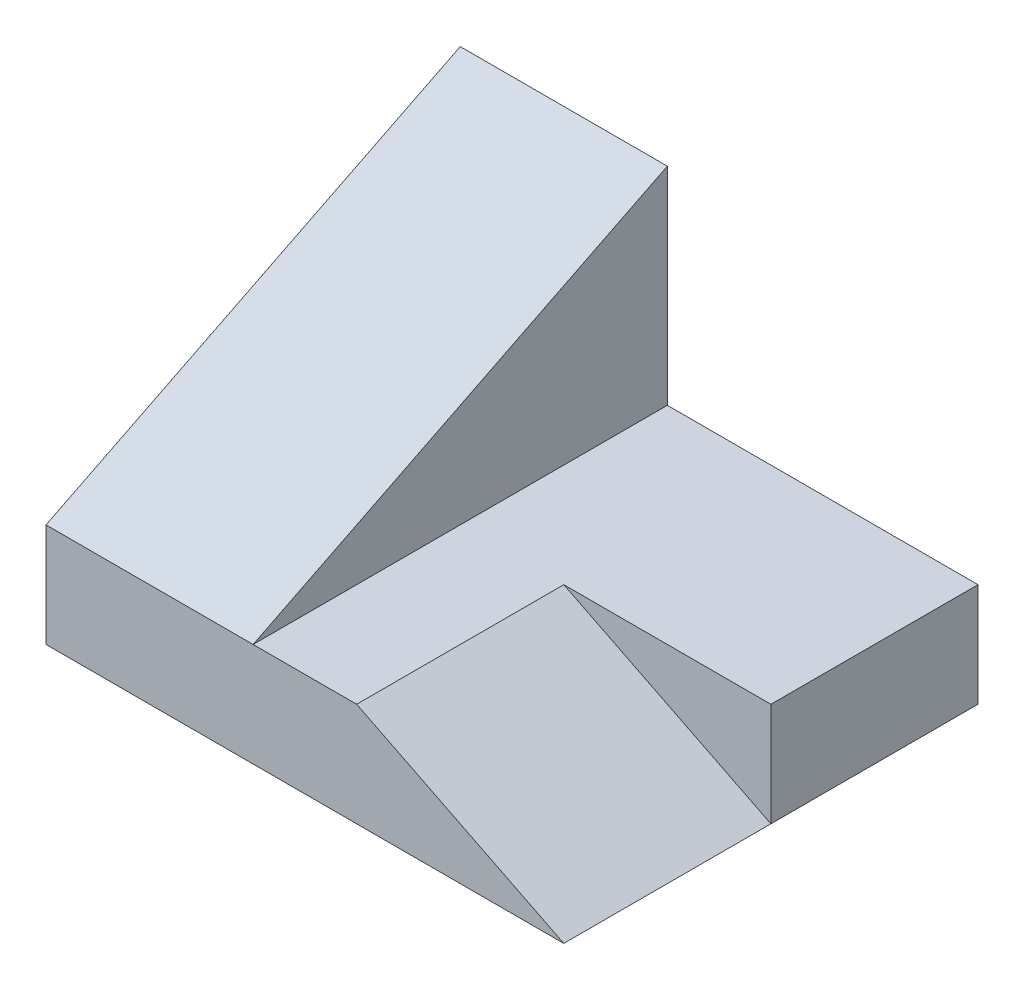
from build123d import *

# Parameters (mm, degrees)
SKETCH5_W               = 50
SKETCH5_H               = 40
BOSS_EXTRUDE5_DEPTH     = 10
SKETCH6_W               = 20
SKETCH6_H               = 40
BOSS_EXTRUDE6_DEPTH     = 20
CUT_EXTRUDE1_DEPTH      = 31
CUT_EXTRUDE1_DEPTH_BACK = 20
CUT_EXTRUDE2_DEPTH      = 1
CUT_EXTRUDE2_DEPTH_BACK = 20


with BuildPart() as part:
    # Sketch5 → Boss-Extrude5 (new body)
    with BuildSketch(Plane(origin=(0, 0, 0), x_dir=(1, 0, 0), z_dir=(0, 1, 0))):
        with Locations((25, 20)):
            Rectangle(SKETCH5_W, SKETCH5_H)
    extrude(amount=BOSS_EXTRUDE5_DEPTH)

    # Sketch6 → Boss-Extrude6 (add)
    with BuildSketch(Plane(origin=(0, 10, 0), x_dir=(1, 0, 0), z_dir=(0, 1, 0))):
        with Locations((10, 20)):
            Rectangle(SKETCH6_W, SKETCH6_H)
    extrude(amount=BOSS_EXTRUDE6_DEPTH)

    # Sketch7 → Cut-Extrude1 (cut, two sides)
    with BuildSketch(Plane(origin=(20, 0, 0), x_dir=(0, 0, -1), z_dir=(1, 0, 0))) as cut_extrude1_sk:
        Polygon((138.38699101, 79.193495505), (40, 30), (0, 10), (-98.38699101, -39.193495505), (-196.77398202, 157.580486515), (40, 275.967477525), align=None)
    extrude(amount=CUT_EXTRUDE1_DEPTH, mode=Mode.SUBTRACT)
    extrude(cut_extrude1_sk.sketch, amount=-CUT_EXTRUDE1_DEPTH_BACK, mode=Mode.SUBTRACT)

    # Sketch8 → Cut-Extrude2 (cut, two sides)
    with BuildSketch(Plane.XY) as cut_extrude2_sk:
        Polygon((176.619037897, 10), (50, 10), (30, 10), (50, 0), (163.251510393, -56.625755197), (411.541457888, -106.441666359), (424.908985391, -39.815911163), align=None)
    extrude(amount=CUT_EXTRUDE2_DEPTH, mode=Mode.SUBTRACT)
    extrude(cut_extrude2_sk.sketch, amount=-CUT_EXTRUDE2_DEPTH_BACK, mode=Mode.SUBTRACT)


solid = part.part
